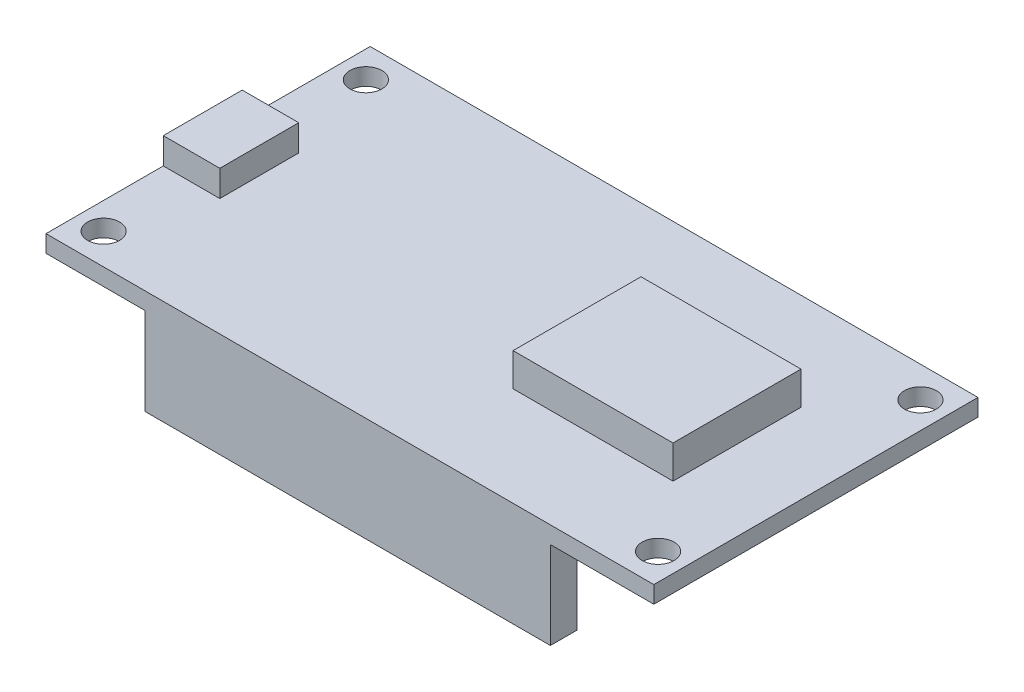
from build123d import *

# Parameters (mm, degrees)
SKETCH_1_W          = 57
SKETCH_1_H          = 30.4
EXTRUDE_1_DEPTH     = 1.6
SKETCH_2_W          = 15
SKETCH_2_H          = 12
EXTRUDE_2_DEPTH     = 3.1
SKETCH_3_W          = 5.3
SKETCH_3_H          = 7.4
EXTRUDE_3_DEPTH     = 2.46
SKETCH_4_R          = 1.5
CUT_EXTRUDE_1_DEPTH = 2.6
SKETCH_5_W          = 38
SKETCH_5_H          = 2.5
EXTRUDE_4_DEPTH     = 8.2


with BuildPart() as part:
    # 草图1 → 凸台-拉伸1 (new body)
    with BuildSketch(Plane(origin=(0, 0, 0), x_dir=(1, 0, 0), z_dir=(0, 1, 0))):
        with Locations((9.099869202, -2.04798995)):
            Rectangle(SKETCH_1_W, SKETCH_1_H)
    extrude(amount=EXTRUDE_1_DEPTH)

    # 草图2 → 凸台-拉伸2 (add)
    with BuildSketch(Plane(origin=(0, 1.6, 0), x_dir=(1, 0, 0), z_dir=(0, 1, 0))):
        with Locations((22.599869202, -1.94798995)):
            Rectangle(SKETCH_2_W, SKETCH_2_H)
    extrude(amount=EXTRUDE_2_DEPTH)

    # 草图3 → 凸台-拉伸3 (add)
    with BuildSketch(Plane(origin=(0, 1.6, 0), x_dir=(1, 0, 0), z_dir=(0, 1, 0))):
        with Locations((-16.750130798, -2.54798995)):
            Rectangle(SKETCH_3_W, SKETCH_3_H)
    extrude(amount=EXTRUDE_3_DEPTH)

    # 草图4 → 切除-拉伸1 (cut, through all)
    with BuildSketch(Plane(origin=(0, 1.6, 0), x_dir=(1, 0, 0), z_dir=(0, 1, 0))):
        with Locations((-16.900130798, 10.25201005)):
            Circle(SKETCH_4_R)
        with Locations((-16.900130798, -14.34798995)):
            Circle(SKETCH_4_R)
        with Locations((35.099869202, -14.34798995)):
            Circle(SKETCH_4_R)
        with Locations((35.099869202, 10.25201005)):
            Circle(SKETCH_4_R)
    extrude(amount=-CUT_EXTRUDE_1_DEPTH, mode=Mode.SUBTRACT)

    # 草图5 → 凸台-拉伸4 (add)
    with BuildSketch(Plane.XZ):
        with Locations((8.899869202, 15.99798995)):
            Rectangle(SKETCH_5_W, SKETCH_5_H)
        with Locations((8.899869202, -11.90201005)):
            Rectangle(SKETCH_5_W, SKETCH_5_H)
    extrude(amount=EXTRUDE_4_DEPTH)


solid = part.part
